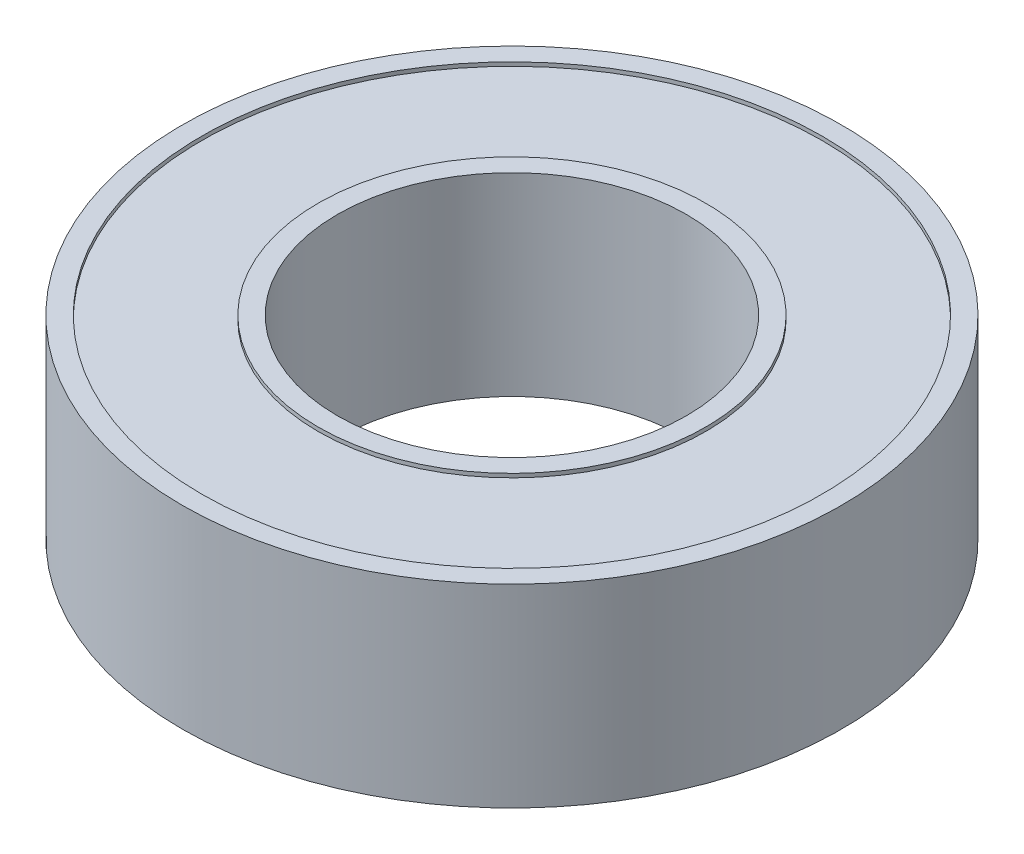
from build123d import *

# Parameters (mm, degrees)
SKETCH1_R           = 8.5
SKETCH1_R_2         = 4.5
BOSS_EXTRUDE1_DEPTH = 2.5
SKETCH2_R           = 8
SKETCH2_R_2         = 5
CUT_EXTRUDE1_DEPTH  = 0.1


with BuildPart() as part:
    # Sketch1 → Boss-Extrude1 (new body, symmetric)
    with BuildSketch(Plane(origin=(0, 0, 0), x_dir=(1, 0, 0), z_dir=(0, 1, 0))):
        Circle(SKETCH1_R)
        Circle(SKETCH1_R_2, mode=Mode.SUBTRACT)
    extrude(amount=BOSS_EXTRUDE1_DEPTH, both=True)

    # Sketch2 → Cut-Extrude1 (cut)
    with BuildSketch(Plane(origin=(0, 2.5, 0), x_dir=(1, 0, 0), z_dir=(0, 1, 0))):
        Circle(SKETCH2_R)
        Circle(SKETCH2_R_2, mode=Mode.SUBTRACT)
    cut_extrude1 = extrude(amount=-CUT_EXTRUDE1_DEPTH, mode=Mode.SUBTRACT)

    # Mirror1: Cut-Extrude1 across plane
    add(cut_extrude1.mirror(Plane.ZX), mode=Mode.SUBTRACT)


solid = part.part
